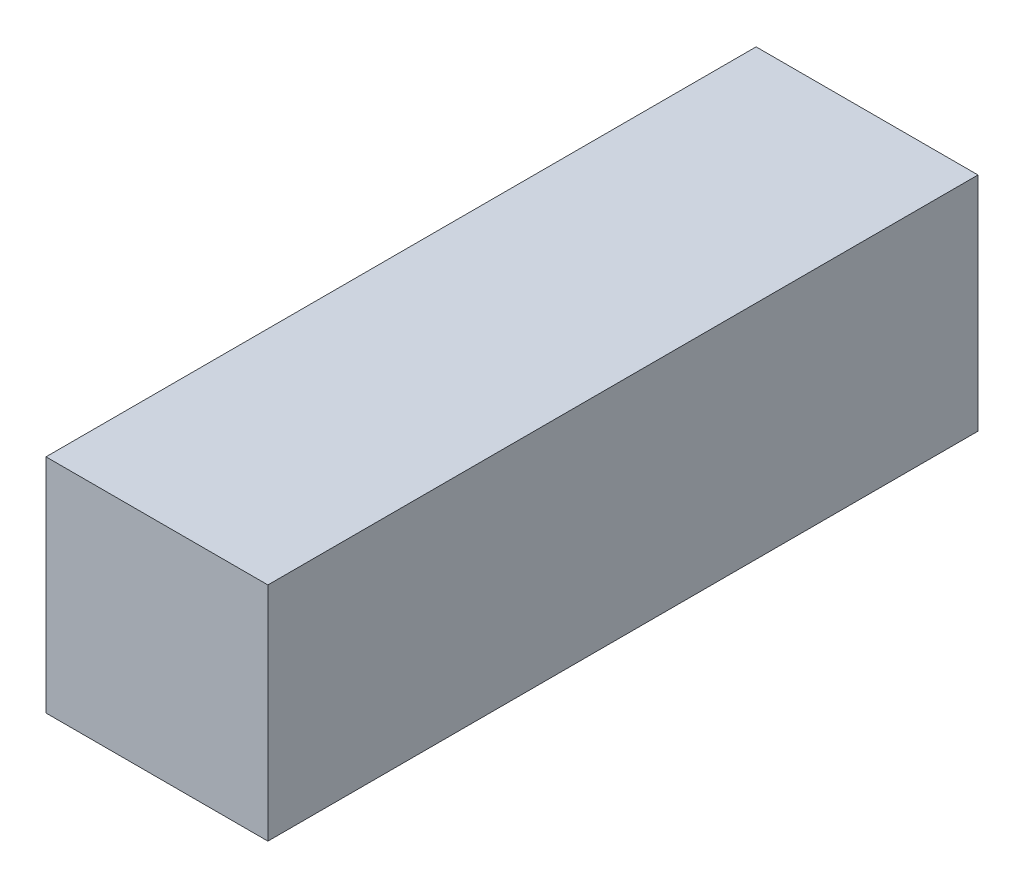
from build123d import *

# Parameters (mm, degrees)
SKETCH1_W           = 35
SKETCH1_H           = 35
BOSS_EXTRUDE1_DEPTH = 112


with BuildPart() as part:
    # Sketch1 → Boss-Extrude1 (new body)
    with BuildSketch(Plane.XY):
        Rectangle(SKETCH1_W, SKETCH1_H)
    extrude(amount=BOSS_EXTRUDE1_DEPTH)


solid = part.part
